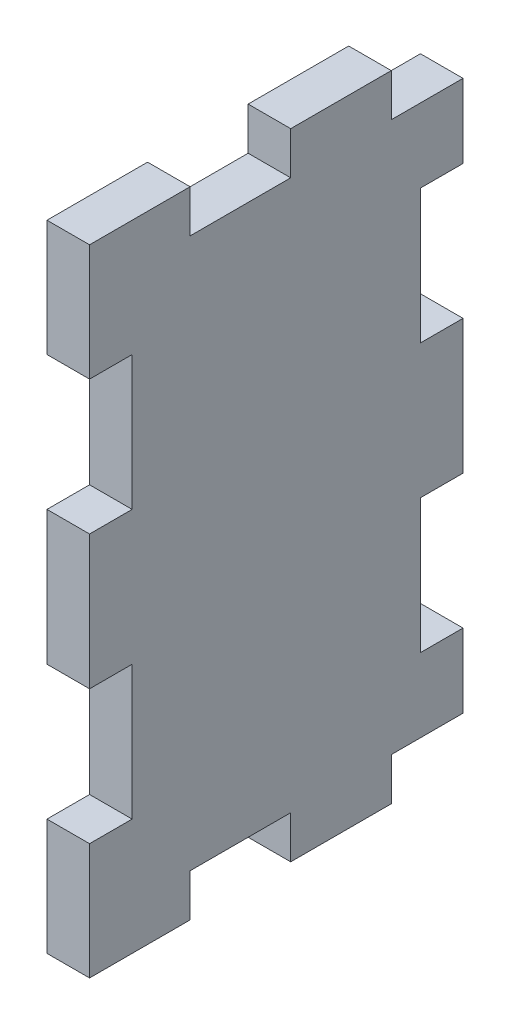
from build123d import *

# Parameters (mm, degrees)
SKETCH1_W           = 35.35
SKETCH1_H           = 47.35
BOSS_EXTRUDE1_DEPTH = 3.175
SKETCH2_W           = 7.5
SKETCH2_H           = 47.35
CUT_EXTRUDE1_DEPTH  = 4.175
SKETCH3_W           = 3.175
SKETCH3_H           = 10
SKETCH3_W_2         = 7.5
SKETCH3_H_2         = 3.175
SKETCH3_W_3         = 5.35
CUT_EXTRUDE2_DEPTH  = 4.175


with BuildPart() as part:
    # Sketch1 → Boss-Extrude1 (new body)
    with BuildSketch(Plane(origin=(0, 0, 0), x_dir=(0, 0, -1), z_dir=(1, 0, 0))):
        with Locations((17.675, 23.675)):
            Rectangle(SKETCH1_W, SKETCH1_H)
    extrude(amount=BOSS_EXTRUDE1_DEPTH)

    # Sketch2 → Cut-Extrude1 (cut, through all)
    with BuildSketch(Plane.ZY):
        with Locations((-31.6, 23.675)):
            Rectangle(SKETCH2_W, SKETCH2_H)
    extrude(amount=-CUT_EXTRUDE1_DEPTH, mode=Mode.SUBTRACT)

    # Sketch3 → Cut-Extrude2 (cut, through all)
    with BuildSketch(Plane.ZY):
        with Locations((-1.5875, 13.675)):
            Rectangle(SKETCH3_W, SKETCH3_H)
        with Locations((-1.5875, 33.675)):
            Rectangle(SKETCH3_W, SKETCH3_H)
        with Locations((-26.2625, 13.675)):
            Rectangle(SKETCH3_W, SKETCH3_H)
        with Locations((-26.2625, 33.675)):
            Rectangle(SKETCH3_W, SKETCH3_H)
        with Locations((-11.25, 45.7625)):
            Rectangle(SKETCH3_W_2, SKETCH3_H_2)
        with Locations((-11.25, 1.5875)):
            Rectangle(SKETCH3_W_2, SKETCH3_H_2)
        with Locations((-25.175, 45.7625)):
            Rectangle(SKETCH3_W_3, SKETCH3_H_2)
        with Locations((-25.175, 1.5875)):
            Rectangle(SKETCH3_W_3, SKETCH3_H_2)
    extrude(amount=-CUT_EXTRUDE2_DEPTH, mode=Mode.SUBTRACT)


solid = part.part
